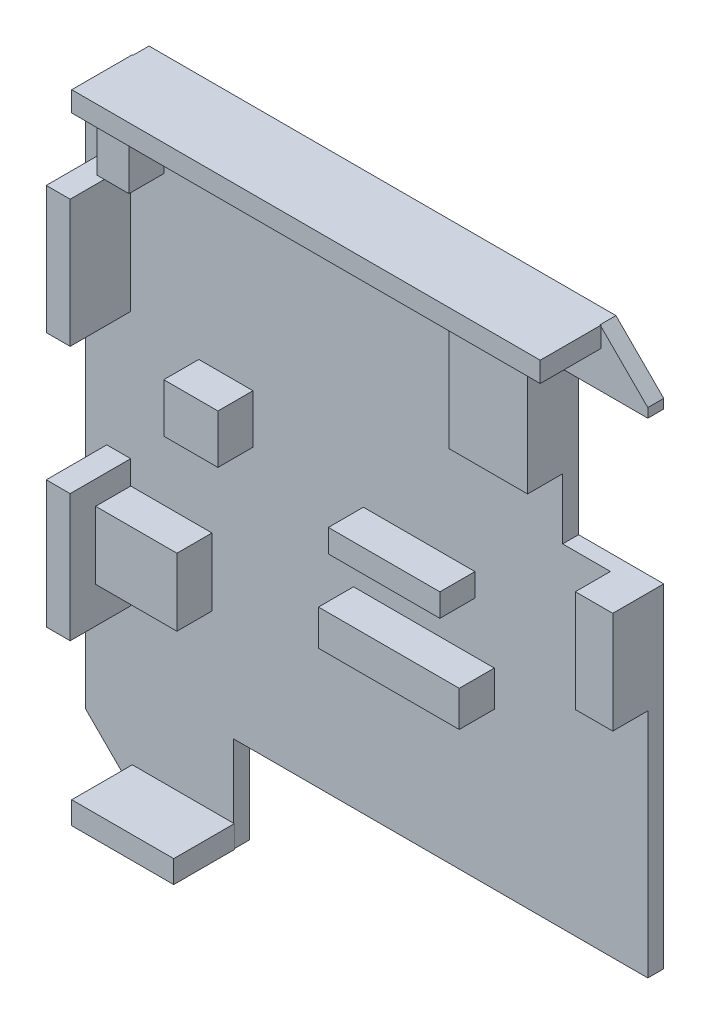
from build123d import *

# Parameters (mm, degrees)
BASE_DEPTH      = 1
SKETCH_2_W      = 5
SKETCH_2_H      = 4.241016002
SKETCH_2_W_2    = 3.399648754
SKETCH_2_H_2    = 3.069015748
SKETCH_2_W_3    = 8.833032766
SKETCH_2_H_3    = 2.239343378
SKETCH_2_W_4    = 7
SKETCH_2_H_4    = 1.440284481
SKETCH_2_W_5    = 2.346977394
SKETCH_2_H_5    = 6.402667005
SKETCH_2_W_6    = 4.921188948
SKETCH_2_H_6    = 7.755318771
SKETCH_2_W_7    = 1.992801626
SKETCH_2_H_7    = 3.770694824
PILLARS_DEPTH   = 2.2
SKETCH_3_W      = 1.5
SKETCH_3_H      = 8
SKETCH_3_W_2    = 29.4
SKETCH_3_H_2    = 1.268554838
SKETCH_3_W_3    = 6.4
SKETCH_3_H_3    = 1.412663195
ENCLOSURE_DEPTH = 3.800051
PADDING_REACH   = 5.2
SKETCH_5_W      = 1.992801626
SKETCH_5_H      = 0.414508298
SKETCH_5_W_2    = 4.921188948
SKETCH_5_H_2    = 0.244108357
SKETCH_5_W_3    = 0.1
SKETCH_5_H_3    = 4.241016002


with BuildPart() as part:
    # 草图1 → Base (new body)
    with BuildSketch(Plane.XY):
        Polygon((14.65, 20), (-14.65, 20), (-17.65, 17), (-17.65, -17), (-14.65, -20), (-8.35, -20), (-8.35, -14), (17.65, -14), (17.65, 6.919667259), (12.305816612, 6.919667259), (12.305816612, 16.420619761), (17.65, 16.420619761), (17.65, 17), align=None)
    extrude(amount=BASE_DEPTH)

    # 草图2 → Pillars (add)
    with BuildSketch(Plane.XY.offset(1)):
        with Locations((-12.199329439, -5.609511049)):
            Rectangle(SKETCH_2_W, SKETCH_2_H)
        with Locations((-8.825830005, 3.993507112)):
            Rectangle(SKETCH_2_W_2, SKETCH_2_H_2)
        with Locations((3.599511049, -3.092672705)):
            Rectangle(SKETCH_2_W_3, SKETCH_2_H_3)
        with Locations((3.303022606, 1.942635256)):
            Rectangle(SKETCH_2_W_4, SKETCH_2_H_4)
        with Locations((16.476511303, 3.718333757)):
            Rectangle(SKETCH_2_W_5, SKETCH_2_H_5)
        with Locations((9.845222138, 14.60967742)):
            Rectangle(SKETCH_2_W_6, SKETCH_2_H_6)
        with Locations((-13.702928626, 16.431589452)):
            Rectangle(SKETCH_2_W_7, SKETCH_2_H_7)
    extrude(amount=PILLARS_DEPTH)

    # 草图3 → Enclosure (add)
    with BuildSketch(Plane.XY.offset(1)):
        with Locations((-15.549329439, 10)):
            Rectangle(SKETCH_3_W, SKETCH_3_H)
        with Locations((0, 19.365722581)):
            Rectangle(SKETCH_3_W_2, SKETCH_3_H_2)
        with Locations((-11.5, -19.293668402)):
            Rectangle(SKETCH_3_W_3, SKETCH_3_H_3)
        with Locations((-15.549329439, -6)):
            Rectangle(SKETCH_3_W, SKETCH_3_H)
    extrude(amount=ENCLOSURE_DEPTH)

    # 草图5 → Padding (add, up to next)
    with BuildSketch(Plane.XY.offset(3.2), mode=Mode.PRIVATE) as padding_sk1:
        with Locations((-13.702928626, 18.524191013)):
            Rectangle(SKETCH_5_W, SKETCH_5_H)
    padding_tool1 = extrude(padding_sk1.sketch, amount=-PADDING_REACH, mode=Mode.PRIVATE) - part.part
    add(padding_tool1.solids().sort_by_distance((-13.702929, 18.524191, 3.2))[0])
    # 草图5 → Padding (add, up to next)
    with BuildSketch(Plane.XY.offset(3.2), mode=Mode.PRIVATE) as padding_sk2:
        with Locations((9.845222138, 18.609390983)):
            Rectangle(SKETCH_5_W_2, SKETCH_5_H_2)
    padding_tool2 = extrude(padding_sk2.sketch, amount=-PADDING_REACH, mode=Mode.PRIVATE) - part.part
    add(padding_tool2.solids().sort_by_distance((9.845222, 18.609391, 3.2))[0])
    # 草图5 → Padding (add, up to next)
    with BuildSketch(Plane.XY.offset(3.2), mode=Mode.PRIVATE) as padding_sk3:
        with Locations((-14.749329439, -5.609511049)):
            Rectangle(SKETCH_5_W_3, SKETCH_5_H_3)
    padding_tool3 = extrude(padding_sk3.sketch, amount=-PADDING_REACH, mode=Mode.PRIVATE) - part.part
    add(padding_tool3.solids().sort_by_distance((-14.749329, -5.609511, 3.2))[0])


solid = part.part
